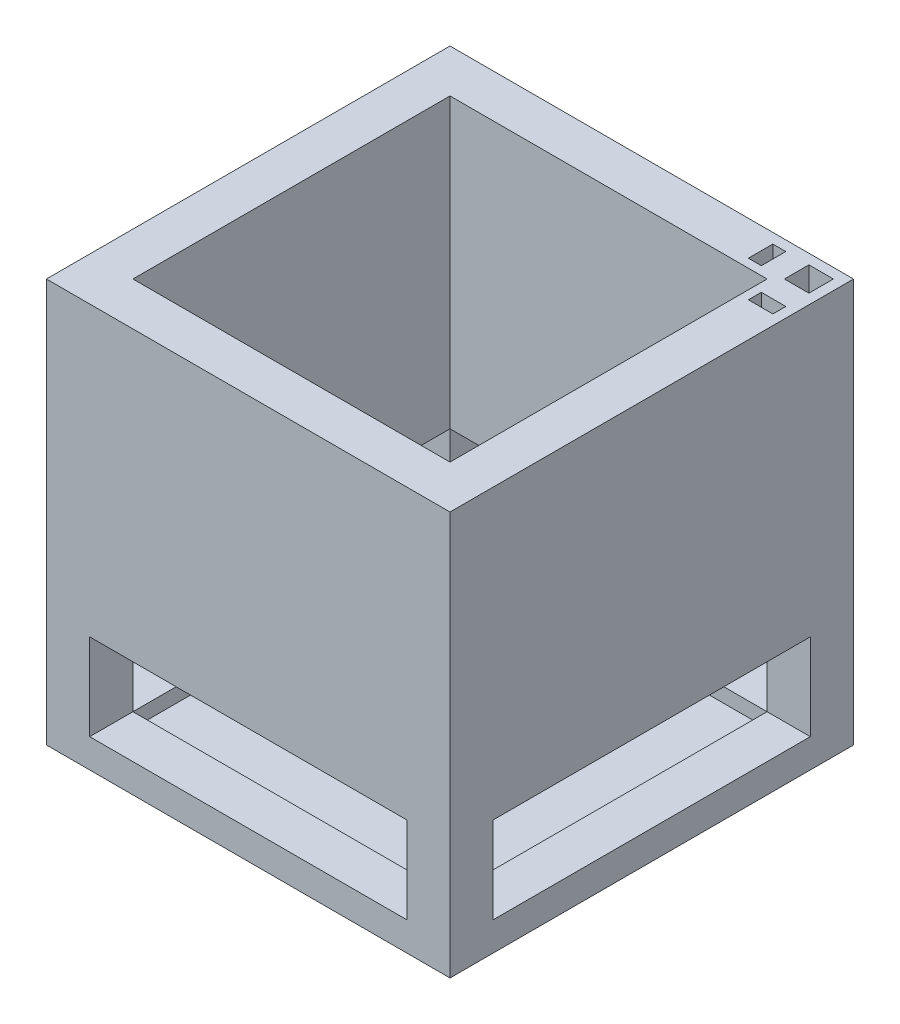
from build123d import *

# Parameters (mm, degrees)
SKETCH1_W               = 140
SKETCH1_H               = 140
BOSS_EXTRUDE1_DEPTH     = 140
SKETCH3_W               = 110
SKETCH3_H               = 110
CUT_EXTRUDE1_DEPTH      = 140
SKETCH4_W               = 140
SKETCH4_H               = 140
BOSS_EXTRUDE2_DEPTH     = 5
SKETCH8_W               = 8.5
SKETCH8_H               = 8.5
CUT_EXTRUDE4_DEPTH      = 140
SKETCH10_W              = 20
SKETCH10_H              = 20
CUT_EXTRUDE5_DEPTH      = 100
SKETCH12_W              = 28.647962974
SKETCH12_H              = 28.734113052
BOSS_EXTRUDE4_DEPTH     = 5
SKETCH18_W              = 23.5
SKETCH18_H              = 15
BOSS_EXTRUDE6_DEPTH     = 70
SKETCH19_W              = 15
SKETCH19_H              = 26.494211046
BOSS_EXTRUDE7_DEPTH     = 70
SKETCH24_W              = 110
SKETCH24_H              = 30
CUT_EXTRUDE8_DEPTH      = 70
CUT_EXTRUDE8_DEPTH_BACK = 70
SKETCH25_W              = 110
SKETCH25_H              = 30
CUT_EXTRUDE9_DEPTH      = 70
CUT_EXTRUDE9_DEPTH_BACK = 70
SKETCH28_W              = 4.5
SKETCH28_H              = 4.5
CUT_EXTRUDE10_DEPTH     = 66.5
SKETCH29_W              = 4.5
SKETCH29_H              = 4.5
CUT_EXTRUDE11_DEPTH     = 66.5
SKETCH30_W              = 4.5
SKETCH30_H              = 4.5
BOSS_EXTRUDE8_DEPTH     = 58
SKETCH32_W              = 4.5
SKETCH32_H              = 4.5
BOSS_EXTRUDE9_DEPTH     = 58
SKETCH34_W              = 58.042814696
SKETCH34_H              = 55
CUT_EXTRUDE20_DEPTH     = 140
SKETCH35_W              = 65.730984893
SKETCH35_H              = 63.694250149
BOSS_EXTRUDE10_DEPTH    = 5


with BuildPart() as part:
    # Sketch1 → Boss-Extrude1 (new body)
    with BuildSketch(Plane(origin=(0, 0, 0), x_dir=(1, 0, 0), z_dir=(0, 1, 0))):
        Rectangle(SKETCH1_W, SKETCH1_H)
    extrude(amount=BOSS_EXTRUDE1_DEPTH)

    # Sketch3 → Cut-Extrude1 (cut)
    with BuildSketch(Plane(origin=(0, 0, 0), x_dir=(1, 0, 0), z_dir=(0, 1, 0))):
        Rectangle(SKETCH3_W, SKETCH3_H)
    extrude(amount=CUT_EXTRUDE1_DEPTH, mode=Mode.SUBTRACT)

    # Sketch4 → Boss-Extrude2 (add)
    with BuildSketch(Plane(origin=(0, 0, 0), x_dir=(1, 0, 0), z_dir=(0, 1, 0))):
        Rectangle(SKETCH4_W, SKETCH4_H)
    extrude(amount=BOSS_EXTRUDE2_DEPTH)

    # Sketch8 → Cut-Extrude4 (cut)
    with BuildSketch(Plane(origin=(0, 0, 0), x_dir=(1, 0, 0), z_dir=(0, 1, 0))):
        with Locations((62.25, 62.25)):
            Rectangle(SKETCH8_W, SKETCH8_H)
    extrude(amount=CUT_EXTRUDE4_DEPTH, mode=Mode.SUBTRACT)

    # Sketch10 → Cut-Extrude5 (cut)
    with BuildSketch(Plane(origin=(0, 0, 0), x_dir=(1, 0, 0), z_dir=(0, 1, 0))):
        with Locations((56.5, 56.5)):
            Rectangle(SKETCH10_W, SKETCH10_H)
    extrude(amount=CUT_EXTRUDE5_DEPTH, mode=Mode.SUBTRACT)

    # Sketch12 → Boss-Extrude4 (add)
    with BuildSketch(Plane(origin=(0, 0, 0), x_dir=(1, 0, 0), z_dir=(0, 1, 0))):
        with Locations((55.676018513, 55.632943474)):
            Rectangle(SKETCH12_W, SKETCH12_H)
    extrude(amount=BOSS_EXTRUDE4_DEPTH)

    # Sketch18 → Boss-Extrude6 (add)
    with BuildSketch(Plane(origin=(0, 0, 0), x_dir=(1, 0, 0), z_dir=(0, 1, 0))):
        with Locations((58.25, 62.5)):
            Rectangle(SKETCH18_W, SKETCH18_H)
    extrude(amount=BOSS_EXTRUDE6_DEPTH)

    # Sketch19 → Boss-Extrude7 (add)
    with BuildSketch(Plane(origin=(0, 0, 0), x_dir=(1, 0, 0), z_dir=(0, 1, 0))):
        with Locations((62.5, 56.752894477)):
            Rectangle(SKETCH19_W, SKETCH19_H)
    extrude(amount=BOSS_EXTRUDE7_DEPTH)

    # Sketch24 → Cut-Extrude8 (cut, two sides)
    with BuildSketch(Plane(origin=(0, 0, 0), x_dir=(0, 0, -1), z_dir=(1, 0, 0))) as cut_extrude8_sk:
        with Locations((0, 25)):
            Rectangle(SKETCH24_W, SKETCH24_H)
    extrude(amount=CUT_EXTRUDE8_DEPTH, mode=Mode.SUBTRACT)
    extrude(cut_extrude8_sk.sketch, amount=-CUT_EXTRUDE8_DEPTH_BACK, mode=Mode.SUBTRACT)

    # Sketch25 → Cut-Extrude9 (cut, two sides)
    with BuildSketch(Plane.XY) as cut_extrude9_sk:
        with Locations((0, 25)):
            Rectangle(SKETCH25_W, SKETCH25_H)
    extrude(amount=CUT_EXTRUDE9_DEPTH, mode=Mode.SUBTRACT)
    extrude(cut_extrude9_sk.sketch, amount=-CUT_EXTRUDE9_DEPTH_BACK, mode=Mode.SUBTRACT)

    # Sketch28 → Cut-Extrude10 (cut)
    with BuildSketch(Plane.XY):
        with Locations((47.75, 137.75)):
            Rectangle(SKETCH28_W, SKETCH28_H)
    extrude(amount=-CUT_EXTRUDE10_DEPTH, mode=Mode.SUBTRACT)

    # Sketch29 → Cut-Extrude11 (cut)
    with BuildSketch(Plane(origin=(0, 0, 0), x_dir=(0, 0, -1), z_dir=(1, 0, 0))):
        with Locations((47.75, 137.75)):
            Rectangle(SKETCH29_W, SKETCH29_H)
    extrude(amount=CUT_EXTRUDE11_DEPTH, mode=Mode.SUBTRACT)

    # Sketch30 → Boss-Extrude8 (add)
    with BuildSketch(Plane.XY):
        with Locations((47.75, 137.75)):
            Rectangle(SKETCH30_W, SKETCH30_H)
    extrude(amount=-BOSS_EXTRUDE8_DEPTH)

    # Sketch32 → Boss-Extrude9 (add)
    with BuildSketch(Plane(origin=(0, 0, 0), x_dir=(0, 0, -1), z_dir=(1, 0, 0))):
        with Locations((47.75, 137.75)):
            Rectangle(SKETCH32_W, SKETCH32_H)
    extrude(amount=BOSS_EXTRUDE9_DEPTH)

    # Sketch34 → Cut-Extrude20 (cut)
    with BuildSketch(Plane(origin=(0, 0, 0), x_dir=(1, 0, 0), z_dir=(0, 1, 0))):
        with Locations((25.978592652, 27.5)):
            Rectangle(SKETCH34_W, SKETCH34_H)
    extrude(amount=CUT_EXTRUDE20_DEPTH, mode=Mode.SUBTRACT)

    # Sketch35 → Boss-Extrude10 (add)
    with BuildSketch(Plane(origin=(0, 0, 0), x_dir=(1, 0, 0), z_dir=(0, 1, 0))):
        with Locations((27.4156276, 28.86339265)):
            Rectangle(SKETCH35_W, SKETCH35_H)
    extrude(amount=BOSS_EXTRUDE10_DEPTH)


solid = part.part
